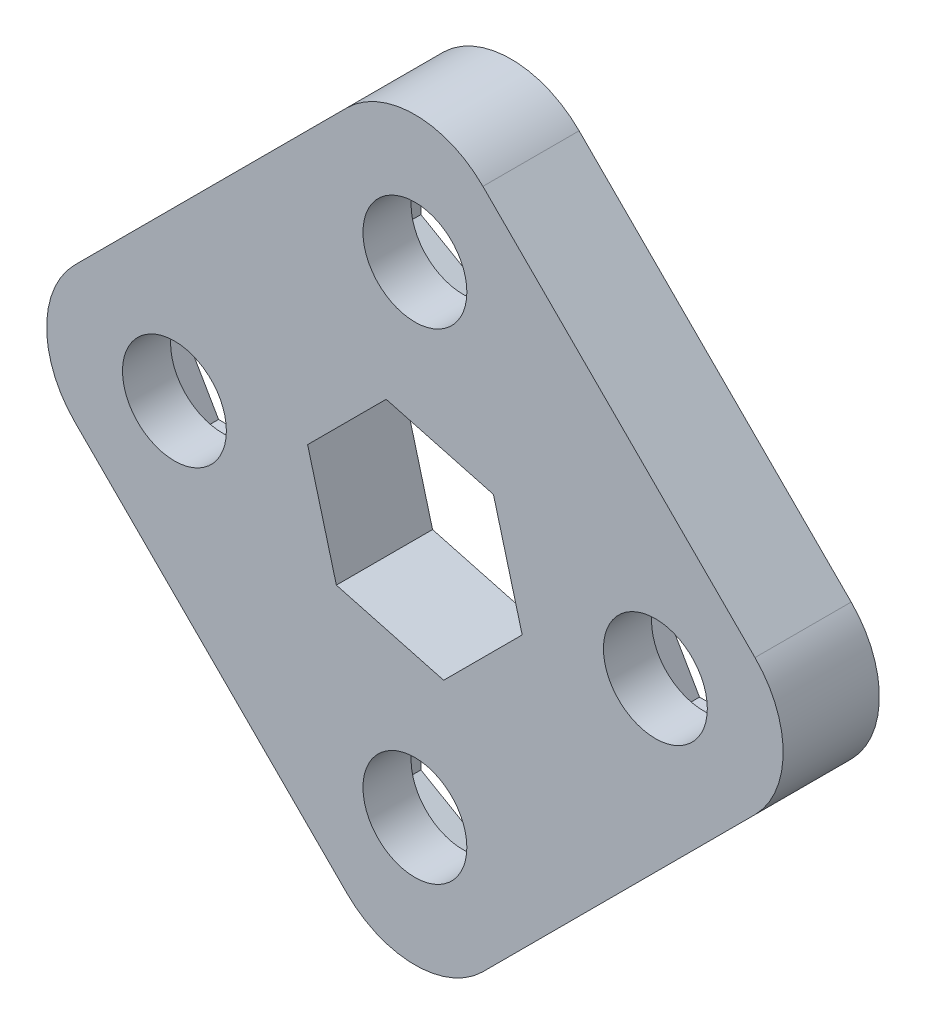
from build123d import *

# Parameters (mm, degrees)
SKETCH2_R           = 3.429
BOSS_EXTRUDE1_DEPTH = 6.35
CUT_EXTRUDE1_DEPTH  = 3.175


with BuildPart() as part:
    # Sketch2 → Boss-Extrude1 (new body)
    with BuildSketch(Plane.XY):
        with BuildLine():
            Line((-4.490128061, 22.450640303), (-22.450640303, 4.490128061))
            ThreePointArc((-22.450640303, 4.490128061), (-24.310512242, 0), (-22.450640303, -4.490128061))
            Line((-22.450640303, -4.490128061), (-4.490128061, -22.450640303))
            ThreePointArc((-4.490128061, -22.450640303), (0, -24.310512242), (4.490128061, -22.450640303))
            Line((4.490128061, -22.450640303), (22.450640303, -4.490128061))
            ThreePointArc((22.450640303, -4.490128061), (24.310512242, 0), (22.450640303, 4.490128061))
            Line((22.450640303, 4.490128061), (4.490128061, 22.450640303))
            ThreePointArc((4.490128061, 22.450640303), (0, 24.310512242), (-4.490128061, 22.450640303))
        make_face()
        with Locations((0, 15.875)):
            Circle(SKETCH2_R, mode=Mode.SUBTRACT)
        with Locations((15.875, 0)):
            Circle(SKETCH2_R, mode=Mode.SUBTRACT)
        with Locations((0, -15.875)):
            Circle(SKETCH2_R, mode=Mode.SUBTRACT)
        with Locations((-15.875, 0)):
            Circle(SKETCH2_R, mode=Mode.SUBTRACT)
        Polygon((5.184753289, 5.184753289), (-1.897751416, 7.082504705), (-7.082504705, 1.897751416), (-5.184753289, -5.184753289), (1.897751416, -7.082504705), (7.082504705, -1.897751416), align=None, mode=Mode.SUBTRACT)
    extrude(amount=BOSS_EXTRUDE1_DEPTH)

    # Sketch3 → Cut-Extrude1 (cut)
    with BuildSketch(Plane(origin=(0, 0, 0), x_dir=(-1, 0, 0), z_dir=(0, 0, -1))):
        Polygon((5.953125, 19.312038321), (0, 22.749076643), (-5.953125, 19.312038321), (-5.953125, 12.437961679), (0, 9.000923357), (5.953125, 12.437961679), align=None)
        Polygon((12.437961679, -5.953125), (19.312038321, -5.953125), (22.749076643, 0), (19.312038321, 5.953125), (12.437961679, 5.953125), (9.000923357, 0), align=None)
        Polygon((-5.953125, -12.437961679), (-5.953125, -19.312038321), (0, -22.749076643), (5.953125, -19.312038321), (5.953125, -12.437961679), (0, -9.000923357), align=None)
        Polygon((-12.437961679, 5.953125), (-19.312038321, 5.953125), (-22.749076643, 0), (-19.312038321, -5.953125), (-12.437961679, -5.953125), (-9.000923357, 0), align=None)
    extrude(amount=-CUT_EXTRUDE1_DEPTH, mode=Mode.SUBTRACT)


solid = part.part
